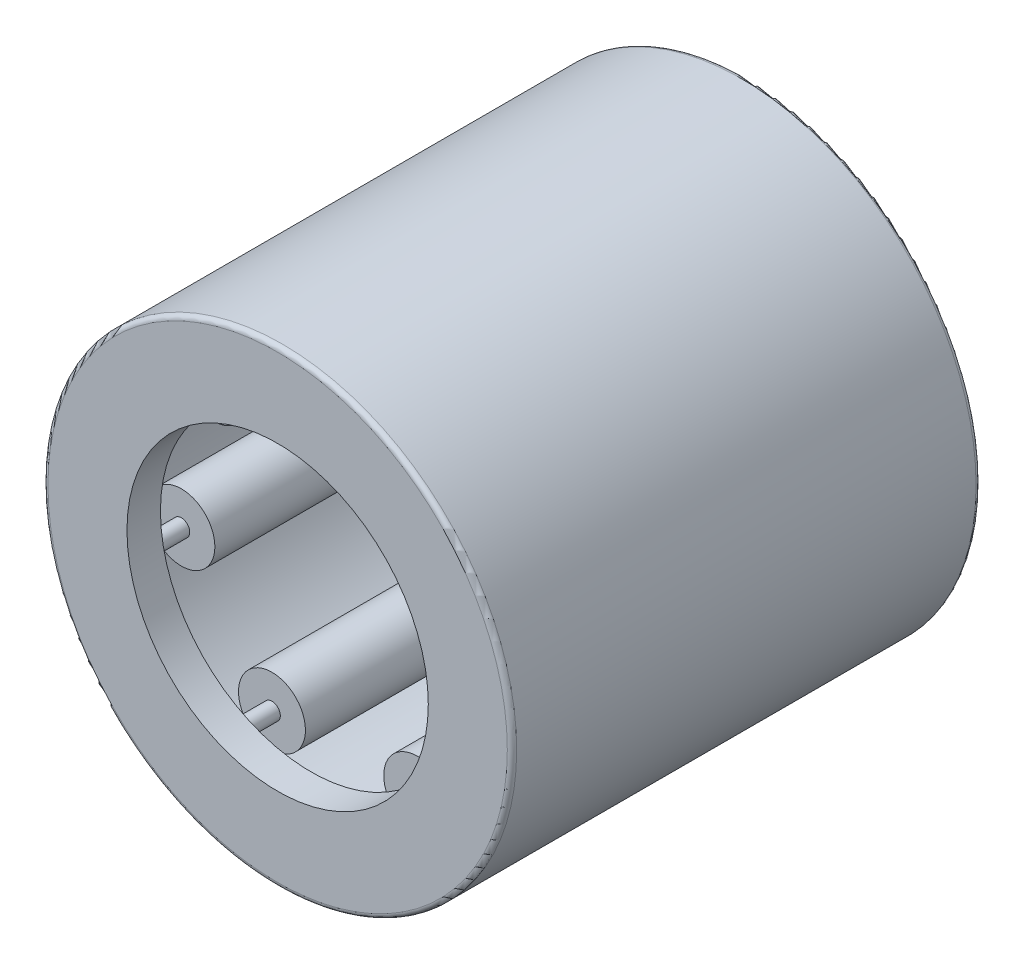
from build123d import *

# Parameters (mm, degrees)
SKETCH2_W         = 7.9375
SKETCH2_H         = 0.5953125
SKETCH3_W         = 9.525
SKETCH3_H         = 0.1984375
CIRPATTERN1_COUNT = 7
CIRPATTERN1_ANGLE = 308.571428571
FILLET1_R         = 0.111125


with BuildPart() as part:
    # Sketch1 → Revolve1 (revolve)
    with BuildSketch(Plane(origin=(0, 0, 0), x_dir=(0, 0, -1), z_dir=(1, 0, 0))):
        Polygon((-5.55625, 5.55625), (5.55625, 5.55625), (5.55625, 3.571875), (4.7625, 3.571875), (4.7625, 4.7625), (-4.7625, 4.7625), (-4.7625, 3.571875), (-5.55625, 3.571875), align=None)
    revolve(axis=Axis((0, 0, 5.55625), (0, 0, -1)))

    # Fillet1
    fillet1_edges = [part.edges().sort_by_distance(p)[0] for p in [
        (0, -5.55625, -5.55625),
        (0, -5.55625, 5.55625),
    ]]
    fillet(fillet1_edges, radius=FILLET1_R)


with BuildPart() as body_2:
    # Sketch2 → Revolve2 (revolve)
    with BuildSketch(Plane(origin=(0, 0, 0), x_dir=(0, 0, -1), z_dir=(1, 0, 0))):
        with Locations((0, 4.46484375)):
            Rectangle(SKETCH2_W, SKETCH2_H)
    revolve(axis=Axis((0, 3.96875, 3.96875), (0, 0, -1)))


with BuildPart() as body_3:
    # Sketch3 → Revolve3 (revolve)
    with BuildSketch(Plane(origin=(0, 0, 0), x_dir=(0, 0, -1), z_dir=(1, 0, 0))):
        with Locations((0, 4.06796875)):
            Rectangle(SKETCH3_W, SKETCH3_H)
    revolve(axis=Axis((0, 3.96875, 4.7625), (0, 0, -1)))


with BuildPart() as cirpattern1_1:
    # CirPattern1: pattern copy
    add(body_2.part.rotate(Axis((0, 0, -5.55625), (0, 0, 1)), 1 * CIRPATTERN1_ANGLE / (CIRPATTERN1_COUNT - 1)))


with BuildPart() as cirpattern1_2:
    # CirPattern1: pattern copy
    add(body_2.part.rotate(Axis((0, 0, -5.55625), (0, 0, 1)), 2 * CIRPATTERN1_ANGLE / (CIRPATTERN1_COUNT - 1)))


with BuildPart() as cirpattern1_3:
    # CirPattern1: pattern copy
    add(body_2.part.rotate(Axis((0, 0, -5.55625), (0, 0, 1)), 3 * CIRPATTERN1_ANGLE / (CIRPATTERN1_COUNT - 1)))


with BuildPart() as cirpattern1_4:
    # CirPattern1: pattern copy
    add(body_2.part.rotate(Axis((0, 0, -5.55625), (0, 0, 1)), 4 * CIRPATTERN1_ANGLE / (CIRPATTERN1_COUNT - 1)))


with BuildPart() as cirpattern1_5:
    # CirPattern1: pattern copy
    add(body_2.part.rotate(Axis((0, 0, -5.55625), (0, 0, 1)), 5 * CIRPATTERN1_ANGLE / (CIRPATTERN1_COUNT - 1)))


with BuildPart() as cirpattern1_6:
    # CirPattern1: pattern copy
    add(body_2.part.rotate(Axis((0, 0, -5.55625), (0, 0, 1)), 6 * CIRPATTERN1_ANGLE / (CIRPATTERN1_COUNT - 1)))


with BuildPart() as cirpattern1_7:
    # CirPattern1: pattern copy
    add(body_3.part.rotate(Axis((0, 0, -5.55625), (0, 0, 1)), 1 * CIRPATTERN1_ANGLE / (CIRPATTERN1_COUNT - 1)))


with BuildPart() as cirpattern1_8:
    # CirPattern1: pattern copy
    add(body_3.part.rotate(Axis((0, 0, -5.55625), (0, 0, 1)), 2 * CIRPATTERN1_ANGLE / (CIRPATTERN1_COUNT - 1)))


with BuildPart() as cirpattern1_9:
    # CirPattern1: pattern copy
    add(body_3.part.rotate(Axis((0, 0, -5.55625), (0, 0, 1)), 3 * CIRPATTERN1_ANGLE / (CIRPATTERN1_COUNT - 1)))


with BuildPart() as cirpattern1_10:
    # CirPattern1: pattern copy
    add(body_3.part.rotate(Axis((0, 0, -5.55625), (0, 0, 1)), 4 * CIRPATTERN1_ANGLE / (CIRPATTERN1_COUNT - 1)))


with BuildPart() as cirpattern1_11:
    # CirPattern1: pattern copy
    add(body_3.part.rotate(Axis((0, 0, -5.55625), (0, 0, 1)), 5 * CIRPATTERN1_ANGLE / (CIRPATTERN1_COUNT - 1)))


with BuildPart() as cirpattern1_12:
    # CirPattern1: pattern copy
    add(body_3.part.rotate(Axis((0, 0, -5.55625), (0, 0, 1)), 6 * CIRPATTERN1_ANGLE / (CIRPATTERN1_COUNT - 1)))


solid = Compound([part.part, body_2.part, body_3.part, cirpattern1_1.part, cirpattern1_2.part, cirpattern1_3.part, cirpattern1_4.part, cirpattern1_5.part, cirpattern1_6.part, cirpattern1_7.part, cirpattern1_8.part, cirpattern1_9.part, cirpattern1_10.part, cirpattern1_11.part, cirpattern1_12.part])
